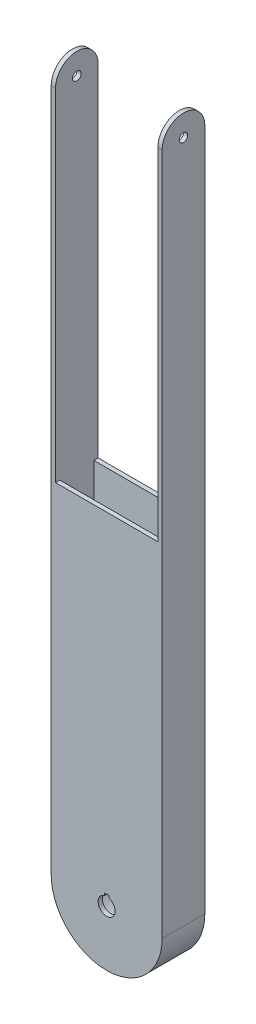
from build123d import *

# Parameters (mm, degrees)
SKETCH2_W           = 82.55
SKETCH2_H           = 31.75
SKETCH2_W_2         = 76.2
SKETCH2_H_2         = 25.4
EXTRUDE_THIN1_DEPTH = 508
BOSS_EXTRUDE2_DEPTH = 31.75
BOSS_EXTRUDE3_DEPTH = 3.175
BOSS_EXTRUDE4_DEPTH = 3.175
SKETCH6_R           = 6.35
SHAFT_HOLE_DEPTH    = 31.75
SKETCH7_W           = 3.175
SKETCH7_H           = 7.9375
KEYWAY_DEPTH        = 31.75
CUT_EXTRUDE1_START  = -76.651281
SKETCH8_R           = 6.35
CUT_EXTRUDE1_DEPTH  = 57.601281
BOSS_EXTRUDE5_DEPTH = 3.175
BOSS_EXTRUDE6_DEPTH = 3.175
CUT_EXTRUDE2_START  = -82.55
SKETCH11_R          = 3.175
CUT_EXTRUDE2_DEPTH  = 82.55
CUT_EXTRUDE3_START  = -31.75
SKETCH12_W          = 76.2
SKETCH12_H          = 254
CUT_EXTRUDE3_DEPTH  = 31.75


with BuildPart() as part:
    # Sketch2 → Extrude-Thin1 (new body)
    with BuildSketch(Plane(origin=(0, 0, 0), x_dir=(1, 0, 0), z_dir=(0, 1, 0))):
        with Locations((22.913756614, 0.671957672)):
            Rectangle(SKETCH2_W, SKETCH2_H)
        with Locations((22.913756614, 0.671957672)):
            Rectangle(SKETCH2_W_2, SKETCH2_H_2, mode=Mode.SUBTRACT)
    extrude(amount=EXTRUDE_THIN1_DEPTH)

    # Sketch3 → Boss-Extrude2 (add)
    with BuildSketch(Plane(origin=(0, 0, -16.546957672), x_dir=(-1, 0, 0), z_dir=(0, 0, -1))):
        with BuildLine():
            Line((-64.188756614, 0), (-48.313756614, 0))
            ThreePointArc((-48.313756614, 0), (-22.913756614, -25.4), (2.486243386, 0))
            Line((2.486243386, 0), (18.361243386, 0))
            ThreePointArc((18.361243386, 0), (-22.913756614, -41.275), (-64.188756614, 0))
        make_face()
    extrude(amount=-BOSS_EXTRUDE2_DEPTH)

    # Sketch4 → Boss-Extrude3 (add)
    with BuildSketch(Plane(origin=(0, 0, -16.546957672), x_dir=(-1, 0, 0), z_dir=(0, 0, -1))):
        with BuildLine():
            Line((-48.313756614, 0), (2.486243386, 0))
            ThreePointArc((2.486243386, 0), (-22.913756614, -25.4), (-48.313756614, 0))
        make_face()
    extrude(amount=-BOSS_EXTRUDE3_DEPTH)

    # Sketch5 → Boss-Extrude4 (add)
    with BuildSketch(Plane.XY.offset(15.203042328)):
        with BuildLine():
            Line((-2.486243386, 0), (48.313756614, 0))
            ThreePointArc((48.313756614, 0), (22.913756614, -25.4), (-2.486243386, 0))
        make_face()
    extrude(amount=-BOSS_EXTRUDE4_DEPTH)

    # Sketch6 → Shaft Hole (cut)
    with BuildSketch(Plane(origin=(0, 0, -16.546957672), x_dir=(-1, 0, 0), z_dir=(0, 0, -1))):
        with Locations((-22.913756614, 0)):
            Circle(SKETCH6_R)
    extrude(amount=-SHAFT_HOLE_DEPTH, mode=Mode.SUBTRACT)

    # Sketch7 → Keyway (cut)
    with BuildSketch(Plane(origin=(0, 0, -16.546957672), x_dir=(-1, 0, 0), z_dir=(0, 0, -1))):
        with Locations((-22.913756614, 3.96875)):
            Rectangle(SKETCH7_W, SKETCH7_H)
    extrude(amount=-KEYWAY_DEPTH, mode=Mode.SUBTRACT)

    # Sketch8 → Cut-Extrude1 (cut)
    with BuildSketch(Plane(origin=(0, 262.273478836, -262.273478836), x_dir=(-1, 0, 0), z_dir=(0, 0.707106781, -0.707106781)).offset(CUT_EXTRUDE1_START)):
        with Locations((-22.913756614, 322.109778865)):
            Circle(SKETCH8_R)
    extrude(amount=CUT_EXTRUDE1_DEPTH, mode=Mode.SUBTRACT)

    # Sketch9 → Boss-Extrude5 (add)
    with BuildSketch(Plane.ZY.offset(18.361243386)):
        with BuildLine():
            Line((-16.546957672, 508), (-3.846957672, 508))
            Line((-3.846957672, 508), (2.503042328, 508))
            Line((2.503042328, 508), (15.203042328, 508))
            ThreePointArc((15.203042328, 508), (-0.671957672, 523.875), (-16.546957672, 508))
        make_face()
    extrude(amount=-BOSS_EXTRUDE5_DEPTH)

    # Sketch10 → Boss-Extrude6 (add)
    with BuildSketch(Plane(origin=(64.188756614, 0, 0), x_dir=(0, 0, -1), z_dir=(1, 0, 0))):
        with BuildLine():
            Line((-12.028042328, 508), (13.371957672, 508))
            Line((13.371957672, 508), (16.546957672, 508))
            ThreePointArc((16.546957672, 508), (0.671957672, 523.875), (-15.203042328, 508))
            Line((-15.203042328, 508), (-12.028042328, 508))
        make_face()
    extrude(amount=-BOSS_EXTRUDE6_DEPTH)

    # Sketch11 → Cut-Extrude2 (cut)
    with BuildSketch(Plane.ZY.offset(18.361243386).offset(CUT_EXTRUDE2_START)):
        with Locations((-0.671957672, 508)):
            Circle(SKETCH11_R)
    extrude(amount=CUT_EXTRUDE2_DEPTH, mode=Mode.SUBTRACT)

    # Sketch12 → Cut-Extrude3 (cut)
    with BuildSketch(Plane(origin=(0, 0, -16.546957672), x_dir=(-1, 0, 0), z_dir=(0, 0, -1)).offset(CUT_EXTRUDE3_START)):
        with Locations((-22.913756614, 381)):
            Rectangle(SKETCH12_W, SKETCH12_H)
    extrude(amount=CUT_EXTRUDE3_DEPTH, mode=Mode.SUBTRACT)


solid = part.part
